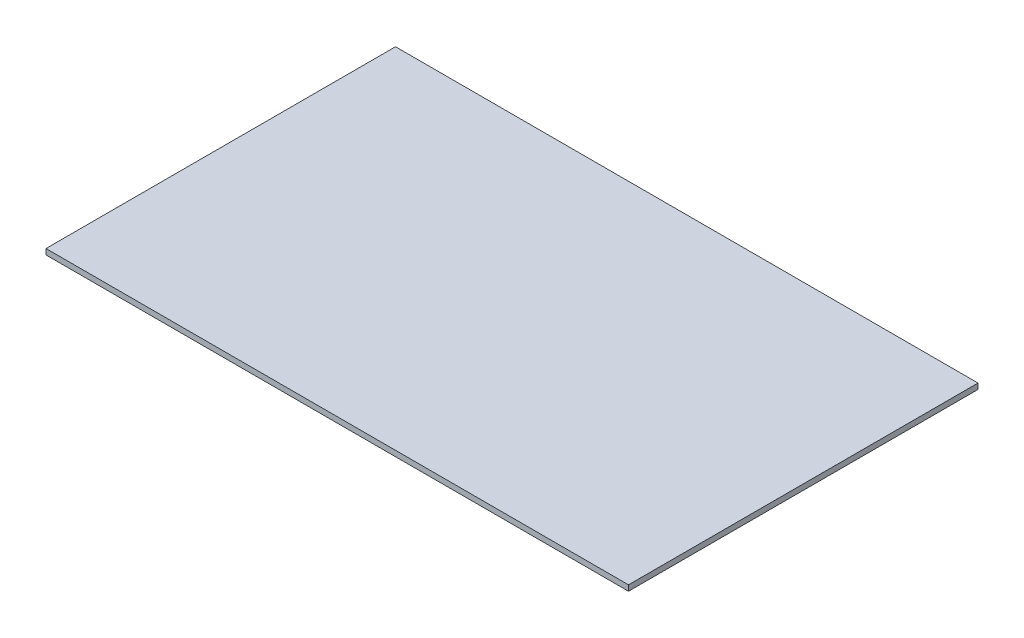
from build123d import *

# Parameters (mm, degrees)
SKETCH1_W           = 125
SKETCH1_H           = 75
BOSS_EXTRUDE1_DEPTH = 1.2


with BuildPart() as part:
    # Sketch1 → Boss-Extrude1 (new body)
    with BuildSketch(Plane(origin=(0, 0, 0), x_dir=(1, 0, 0), z_dir=(0, 1, 0))):
        Rectangle(SKETCH1_W, SKETCH1_H)
    extrude(amount=BOSS_EXTRUDE1_DEPTH)


solid = part.part
